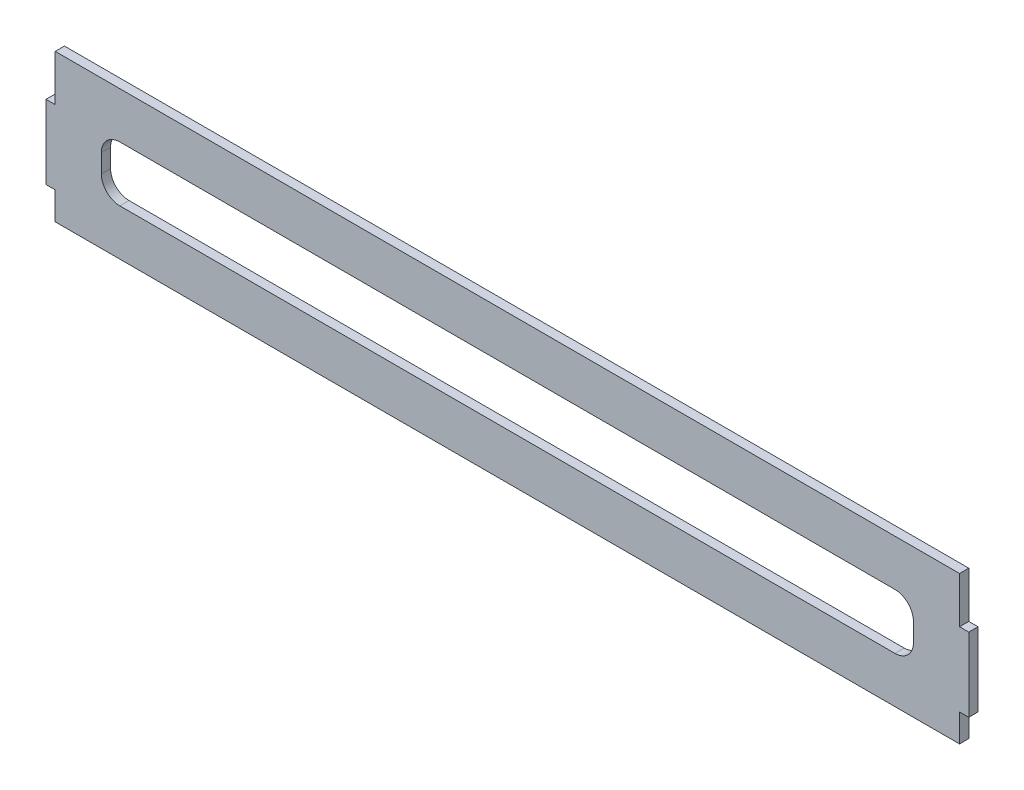
from build123d import *

# Parameters (mm, degrees)
BOSS_EXTRU_1_DEPTH      = 5
ENL_V_MAT_EXTRU_1_REACH = 7


with BuildPart() as part:
    # Esquisse1 → Boss.-Extru.1 (new body)
    with BuildSketch(Plane.XY):
        Polygon((0, 0), (0, 15), (-5, 15), (-5, 55), (0, 55), (0, 80), (490, 80), (490, 55), (495, 55), (495, 15), (490, 15), (490, 0), align=None)
    extrude(amount=BOSS_EXTRU_1_DEPTH)

    # Esquisse2 → Enlèv. mat.-Extru.1 (cut, up to next)
    with BuildSketch(Plane.XY.offset(5), mode=Mode.PRIVATE) as enl_v_mat_extru_1_sk1:
        with BuildLine():
            Line((35, 25), (455, 25))
            ThreePointArc((455, 25), (462.071067812, 27.928932188), (465, 35))
            Line((465, 35), (465, 45))
            ThreePointArc((465, 45), (462.071067812, 52.071067812), (455, 55))
            Line((455, 55), (35, 55))
            ThreePointArc((35, 55), (27.928932188, 52.071067812), (25, 45))
            Line((25, 45), (25, 35))
            ThreePointArc((25, 35), (27.928932188, 27.928932188), (35, 25))
        make_face()
    enl_v_mat_extru_1_tool1 = extrude(enl_v_mat_extru_1_sk1.sketch, amount=-ENL_V_MAT_EXTRU_1_REACH, mode=Mode.PRIVATE) & part.part
    add(enl_v_mat_extru_1_tool1.solids().sort_by_distance((245, 40, 5))[0], mode=Mode.SUBTRACT)


solid = part.part
